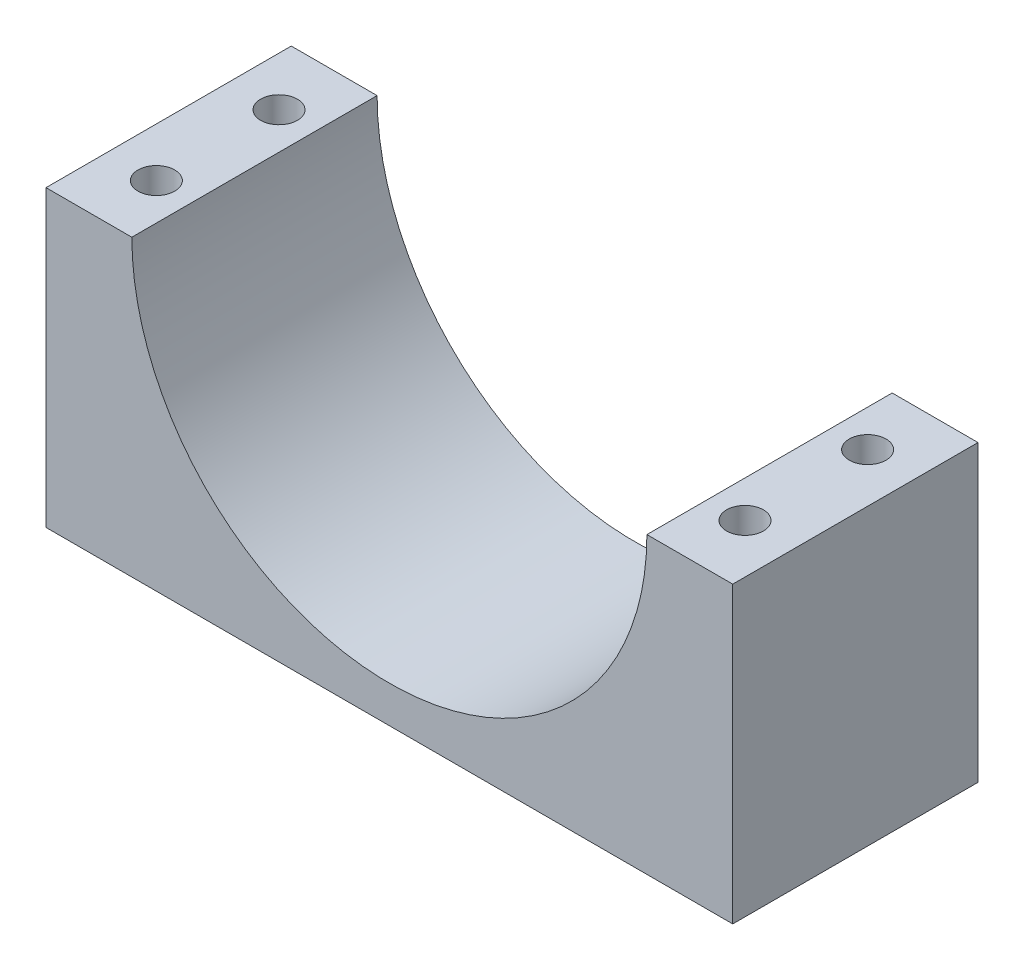
from build123d import *

# Parameters (mm, degrees)
EXTRUDE_1_DEPTH     = 20
SKETCH_2_R          = 1.5
CUT_EXTRUDE_1_DEPTH = 25


with BuildPart() as part:
    # 草图1 → 凸台-拉伸1 (new body)
    with BuildSketch(Plane.XY):
        with BuildLine():
            Line((-28, -24), (28, -24))
            Line((28, -24), (28, 0))
            Line((28, 0), (21, 0))
            ThreePointArc((21, 0), (0, -21), (-21, 0))
            Line((-21, 0), (-28, 0))
            Line((-28, 0), (-28, -24))
        make_face()
    extrude(amount=EXTRUDE_1_DEPTH)

    # 草图2 → 切除-拉伸1 (cut, through all)
    with BuildSketch(Plane(origin=(0, 0, 0), x_dir=(1, 0, 0), z_dir=(0, 1, 0))):
        with Locations((-24, -5)):
            Circle(SKETCH_2_R)
        with Locations((-24, -15)):
            Circle(SKETCH_2_R)
    cut_extrude_1 = extrude(amount=-CUT_EXTRUDE_1_DEPTH, mode=Mode.SUBTRACT)

    # 镜向1: 切除-拉伸1 across plane
    add(cut_extrude_1.mirror(Plane(origin=(0, 0, 0), x_dir=(0, 0, 1), z_dir=(1, 0, 0))), mode=Mode.SUBTRACT)


solid = part.part
